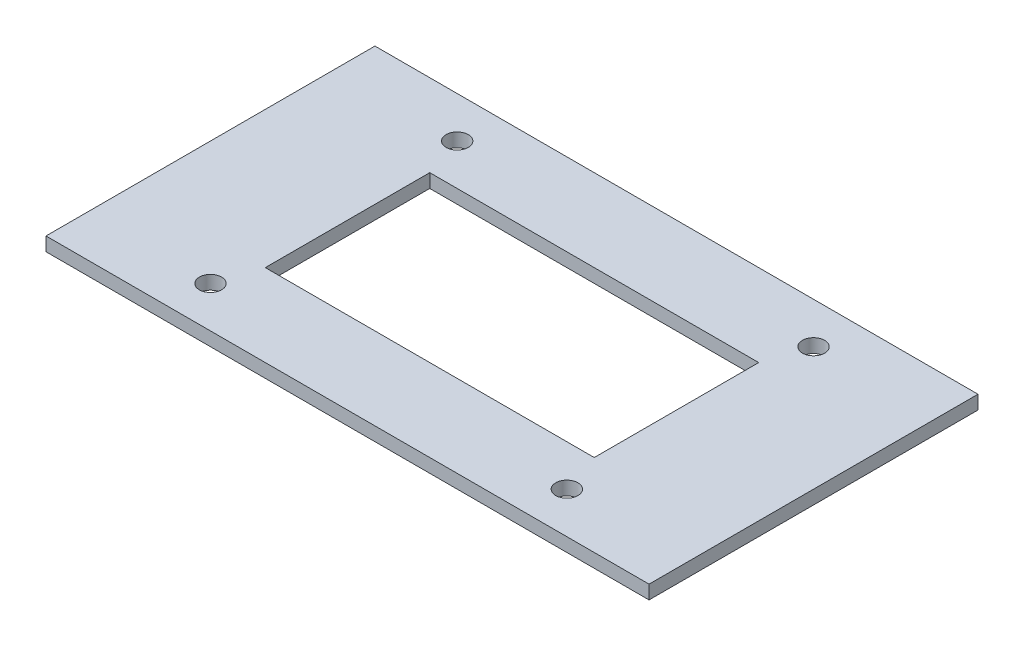
from build123d import *

# Parameters (mm, degrees)
SKETCH1_W           = 558.8
SKETCH1_H           = 304.8
BOSS_EXTRUDE1_DEPTH = 12.7
SKETCH2_W           = 304.8
SKETCH2_H           = 152.4
CUT_EXTRUDE1_DEPTH  = 12.7
SKETCH4_R           = 10.287
CUT_EXTRUDE2_DEPTH  = 12.7


with BuildPart() as part:
    # Sketch1 → Boss-Extrude1 (new body)
    with BuildSketch(Plane(origin=(0, 0, 0), x_dir=(1, 0, 0), z_dir=(0, 1, 0))):
        with Locations((219.899775418, -105.5355758)):
            Rectangle(SKETCH1_W, SKETCH1_H)
    extrude(amount=BOSS_EXTRUDE1_DEPTH)

    # Sketch2 → Cut-Extrude1 (cut)
    with BuildSketch(Plane(origin=(0, 12.7, 0), x_dir=(1, 0, 0), z_dir=(0, 1, 0))):
        with Locations((219.899775418, -105.5355758)):
            Rectangle(SKETCH2_W, SKETCH2_H)
    extrude(amount=-CUT_EXTRUDE1_DEPTH, mode=Mode.SUBTRACT)

    # Sketch4 → Cut-Extrude2 (cut)
    with BuildSketch(Plane(origin=(0, 12.7, 0), x_dir=(1, 0, 0), z_dir=(0, 1, 0))):
        with Locations((54.799775418, 8.7644242)):
            Circle(SKETCH4_R)
        with Locations((384.999775418, 8.7644242)):
            Circle(SKETCH4_R)
        with Locations((54.799775418, -219.8355758)):
            Circle(SKETCH4_R)
        with Locations((384.999775418, -219.8355758)):
            Circle(SKETCH4_R)
    extrude(amount=-CUT_EXTRUDE2_DEPTH, mode=Mode.SUBTRACT)


solid = part.part
